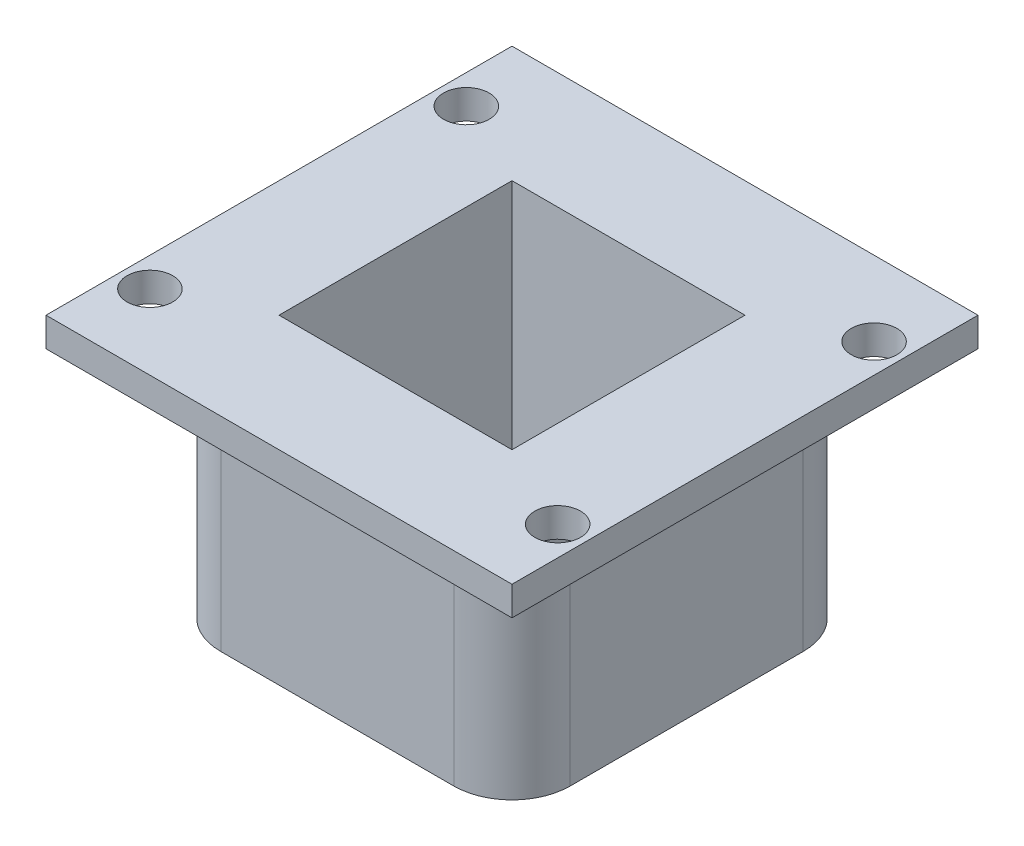
from build123d import *

# Parameters (mm, degrees)
SKETCH1_W           = 50.8
SKETCH1_H           = 50.8
SKETCH1_R           = 2.4892
BOSS_EXTRUDE1_DEPTH = 3.175
BOSS_EXTRUDE2_DEPTH = 25.4
SKETCH2_W           = 25.4
SKETCH2_H           = 25.4
CUT_EXTRUDE1_DEPTH  = 29.575


with BuildPart() as part:
    # Sketch1 → Boss-Extrude1 (new body)
    with BuildSketch(Plane(origin=(0, 0, 0), x_dir=(1, 0, 0), z_dir=(0, 1, 0))):
        Rectangle(SKETCH1_W, SKETCH1_H)
        with Locations((-22.225, 17.2466)):
            Circle(SKETCH1_R, mode=Mode.SUBTRACT)
        with Locations((22.225, 17.2466)):
            Circle(SKETCH1_R, mode=Mode.SUBTRACT)
        with Locations((22.225, -17.2466)):
            Circle(SKETCH1_R, mode=Mode.SUBTRACT)
        with Locations((-22.225, -17.2466)):
            Circle(SKETCH1_R, mode=Mode.SUBTRACT)
    extrude(amount=BOSS_EXTRUDE1_DEPTH)

    # Sketch1_3 → Boss-Extrude2 (add)
    with BuildSketch(Plane(origin=(0, 0, 0), x_dir=(1, 0, 0), z_dir=(0, 1, 0))):
        with BuildLine():
            ThreePointArc((-19.05, -12.7), (-17.190128061, -17.190128061), (-12.7, -19.05))
            Line((-12.7, -19.05), (12.7, -19.05))
            ThreePointArc((12.7, -19.05), (17.190128061, -17.190128061), (19.05, -12.7))
            Line((19.05, -12.7), (19.05, 12.7))
            ThreePointArc((19.05, 12.7), (17.190128061, 17.190128061), (12.7, 19.05))
            Line((12.7, 19.05), (-12.7, 19.05))
            ThreePointArc((-12.7, 19.05), (-17.190128061, 17.190128061), (-19.05, 12.7))
            Line((-19.05, 12.7), (-19.05, -12.7))
        make_face()
    extrude(amount=-BOSS_EXTRUDE2_DEPTH)

    # Sketch2 → Cut-Extrude1 (cut, through all)
    with BuildSketch(Plane(origin=(0, 3.175, 0), x_dir=(1, 0, 0), z_dir=(0, 1, 0))):
        Rectangle(SKETCH2_W, SKETCH2_H)
    extrude(amount=-CUT_EXTRUDE1_DEPTH, mode=Mode.SUBTRACT)


solid = part.part
